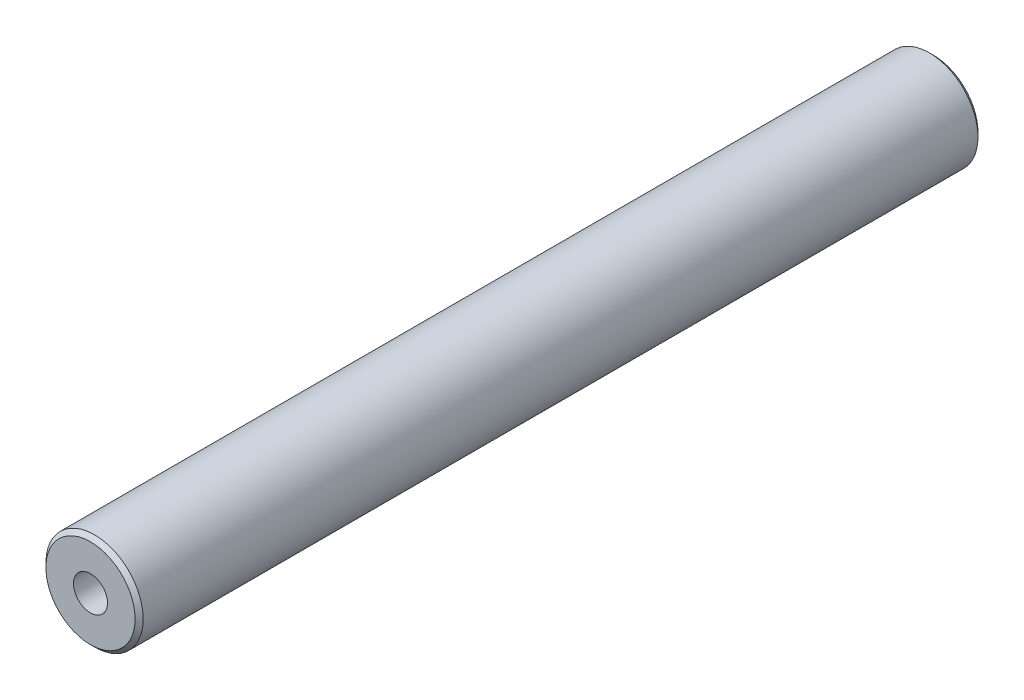
from build123d import *

# Parameters (mm, degrees)
ESQUISSE1_R               = 6
BOSS_EXTRU_1_DEPTH        = 104
TROU_TARAUD_M5X0_81_D     = 4.2
TROU_TARAUD_M5X0_81_DEPTH = 20
TROU_TARAUD_M5X0_81_TIP   = 1.2618073
TROU_TARAUD_M5X0_82_D     = 4.2
TROU_TARAUD_M5X0_82_DEPTH = 20
TROU_TARAUD_M5X0_82_TIP   = 1.2618073
CHANFREIN1_SIZE           = 0.5


with BuildPart() as part:
    # Esquisse1 → Boss.-Extru.1 (new body)
    with BuildSketch(Plane.XY):
        Circle(ESQUISSE1_R)
    extrude(amount=BOSS_EXTRU_1_DEPTH)

    # Trou taraudé M5x0.81
    with Locations(Plane(origin=(0, 0, 0), x_dir=(-1, 0, 0), z_dir=(0, 0, -1))):
        with Locations((0, 0)):
            Hole(TROU_TARAUD_M5X0_81_D / 2, depth=TROU_TARAUD_M5X0_81_DEPTH)
            with Locations((0, 0, -(TROU_TARAUD_M5X0_81_DEPTH + TROU_TARAUD_M5X0_81_TIP / 2))):  # 118° drill point
                Cone(0, TROU_TARAUD_M5X0_81_D / 2, TROU_TARAUD_M5X0_81_TIP, mode=Mode.SUBTRACT)

    # Trou taraudé M5x0.82
    with Locations(Plane.XY.offset(104)):
        with Locations((0, 0)):
            Hole(TROU_TARAUD_M5X0_82_D / 2, depth=TROU_TARAUD_M5X0_82_DEPTH)
            with Locations((0, 0, -(TROU_TARAUD_M5X0_82_DEPTH + TROU_TARAUD_M5X0_82_TIP / 2))):  # 118° drill point
                Cone(0, TROU_TARAUD_M5X0_82_D / 2, TROU_TARAUD_M5X0_82_TIP, mode=Mode.SUBTRACT)

    # Chanfrein1
    chanfrein1_edges = [part.edges().sort_by_distance(p)[0] for p in [
        (-6, 0, 0),
        (-6, 0, 104),
    ]]
    chamfer(chanfrein1_edges, length=CHANFREIN1_SIZE)


solid = part.part
